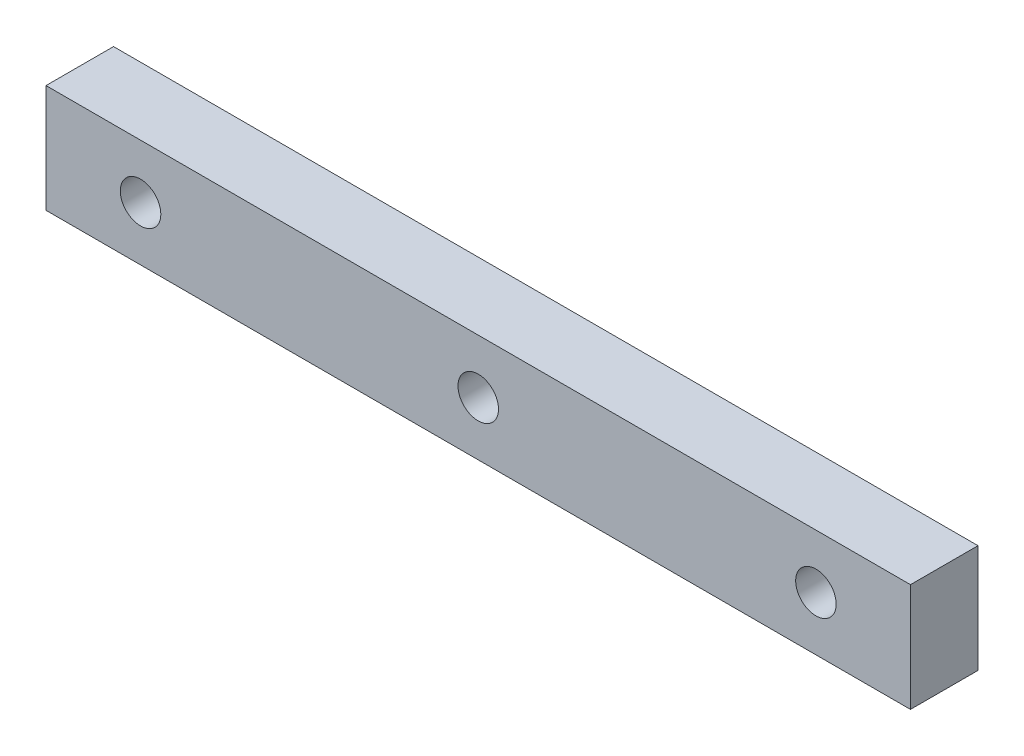
from build123d import *

# Parameters (mm, degrees)
SKETCH1_W           = 64
SKETCH1_H           = 8
BOSS_EXTRUDE1_DEPTH = 5
SKETCH2_R           = 1.5
CUT_EXTRUDE1_DEPTH  = 10


with BuildPart() as part:
    # Sketch1 → Boss-Extrude1 (new body)
    with BuildSketch(Plane.XY):
        Rectangle(SKETCH1_W, SKETCH1_H)
    extrude(amount=BOSS_EXTRUDE1_DEPTH)

    # Sketch2 → Cut-Extrude1 (cut)
    with BuildSketch(Plane(origin=(0, 0, 0), x_dir=(-1, 0, 0), z_dir=(0, 0, -1))):
        with Locations((-25, 0)):
            Circle(SKETCH2_R)
        Circle(SKETCH2_R)
        with Locations((25, 0)):
            Circle(SKETCH2_R)
    extrude(amount=-CUT_EXTRUDE1_DEPTH, mode=Mode.SUBTRACT)


solid = part.part
